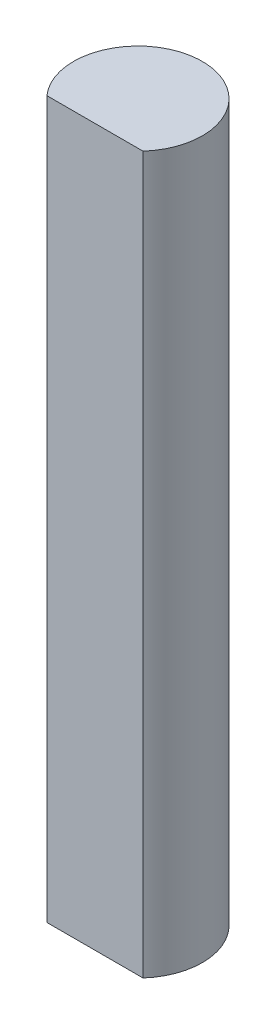
from build123d import *

# Parameters (mm, degrees)
SKETCH2_R           = 2.25
BOSS_EXTRUDE1_DEPTH = 25
SKETCH4_W           = 4.625136888
SKETCH4_H           = 0.896227251
CUT_EXTRUDE1_DEPTH  = 25


with BuildPart() as part:
    # Sketch2 → Boss-Extrude1 (new body)
    with BuildSketch(Plane(origin=(0, 0, 0), x_dir=(1, 0, 0), z_dir=(0, 1, 0))):
        Circle(SKETCH2_R)
    extrude(amount=BOSS_EXTRUDE1_DEPTH)

    # Sketch4 → Cut-Extrude1 (cut)
    with BuildSketch(Plane(origin=(0, 25, 0), x_dir=(1, 0, 0), z_dir=(0, 1, 0))):
        with Locations((0, -1.948113626)):
            Rectangle(SKETCH4_W, SKETCH4_H)
    extrude(amount=-CUT_EXTRUDE1_DEPTH, mode=Mode.SUBTRACT)


solid = part.part
